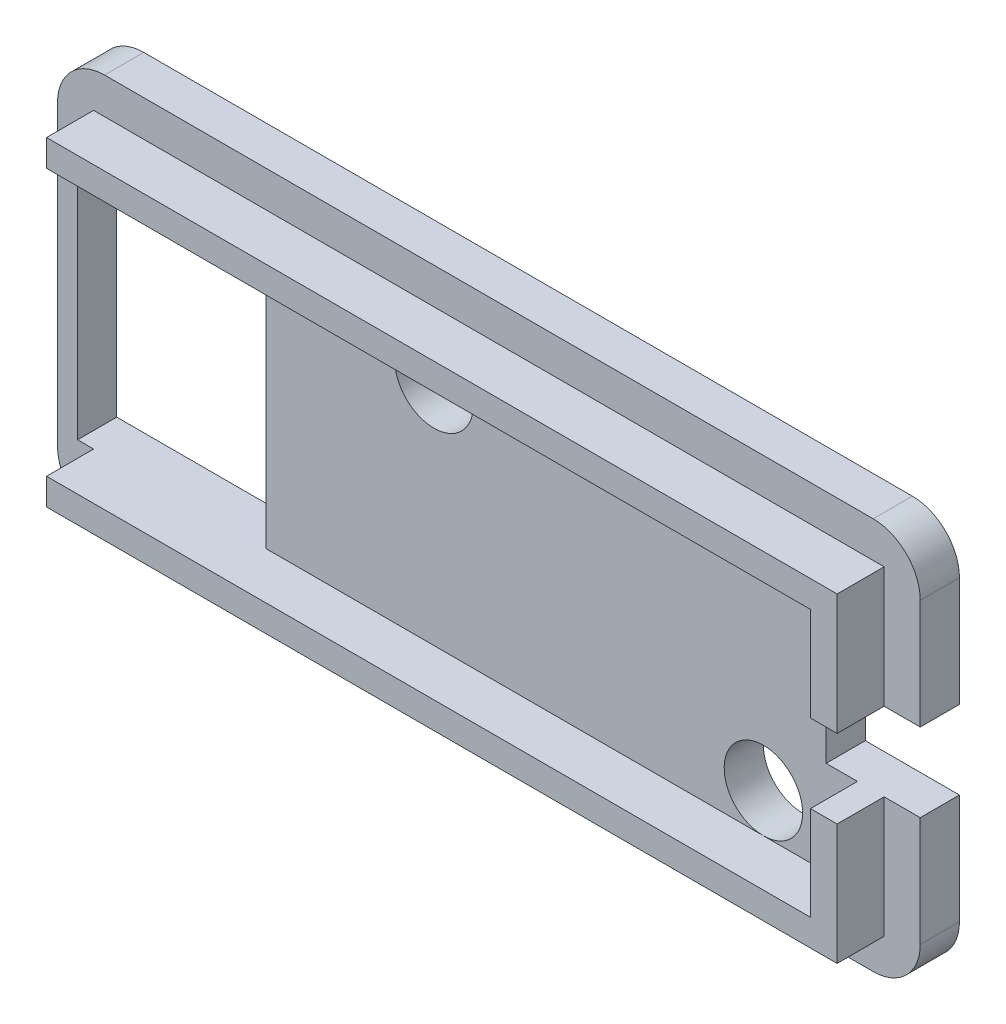
from build123d import *

# Parameters (mm, degrees)
CROQUIS1_W                 = 55
CROQUIS1_H                 = 25
SALIENTE_EXTRUIR1_DEPTH    = 2.5
CROQUIS7_W                 = 51
CROQUIS7_H                 = 21
CROQUIS7_W_2               = 47
CROQUIS7_H_2               = 17
SALIENTE_EXTRUIR4_DEPTH    = 3
REDONDEO2_R                = 3
CROQUIS8_W                 = 12
CROQUIS8_H                 = 17
CORTAR_EXTRUIR5_DEPTH      = 11
CORTAR_EXTRUIR5_DEPTH_BACK = 8
CROQUIS9_W                 = 6
CROQUIS9_H                 = 5
CORTAR_EXTRUIR6_DEPTH      = 8
CROQUIS11_R                = 2.5
CORTAR_EXTRUIR8_DEPTH      = 3.5
CROQUIS12_W                = 51
CROQUIS12_H                = 21
CROQUIS12_W_2              = 50.4
CROQUIS12_H_2              = 20.4
CORTAR_EXTRUIR11_DEPTH     = 3


with BuildPart() as part:
    # Croquis1 → Saliente-Extruir1 (new body)
    with BuildSketch(Plane.XY):
        Rectangle(CROQUIS1_W, CROQUIS1_H)
    extrude(amount=SALIENTE_EXTRUIR1_DEPTH)

    # Croquis7 → Saliente-Extruir4 (add)
    with BuildSketch(Plane.XY.offset(2.5)):
        Rectangle(CROQUIS7_W, CROQUIS7_H)
        Rectangle(CROQUIS7_W_2, CROQUIS7_H_2, mode=Mode.SUBTRACT)
    extrude(amount=SALIENTE_EXTRUIR4_DEPTH)

    # Redondeo2
    redondeo2_edges = [part.edges().sort_by_distance(p)[0] for p in [
        (-27.5, -12.5, 1.25),
        (-27.5, 12.5, 1.25),
        (27.5, 12.5, 1.25),
        (27.5, -12.5, 1.25),
    ]]
    fillet(redondeo2_edges, radius=REDONDEO2_R)

    # Croquis8 → Cortar-Extruir5 (cut, two sides)
    with BuildSketch(Plane.XY.offset(2.5)) as cortar_extruir5_sk:
        with Locations((-20.225004992, 0)):
            Rectangle(CROQUIS8_W, CROQUIS8_H)
    extrude(amount=CORTAR_EXTRUIR5_DEPTH, mode=Mode.SUBTRACT)
    extrude(cortar_extruir5_sk.sketch, amount=-CORTAR_EXTRUIR5_DEPTH_BACK, mode=Mode.SUBTRACT)

    # Croquis9 → Cortar-Extruir6 (cut)
    with BuildSketch(Plane(origin=(0, 0, 0), x_dir=(-1, 0, 0), z_dir=(0, 0, -1))):
        with Locations((-24.5, 0)):
            Rectangle(CROQUIS9_W, CROQUIS9_H)
    extrude(amount=-CORTAR_EXTRUIR6_DEPTH, mode=Mode.SUBTRACT)

    # Croquis11 → Cortar-Extruir8 (cut, through all)
    with BuildSketch(Plane.XY.offset(2.5)):
        with Locations((-3.5, 6)):
            Circle(CROQUIS11_R)
        with Locations((17.5, -6)):
            Circle(CROQUIS11_R)
    extrude(amount=-CORTAR_EXTRUIR8_DEPTH, mode=Mode.SUBTRACT)

    # Croquis12 → Cortar-Extruir11 (cut)
    with BuildSketch(Plane.XY.offset(5.5)):
        Rectangle(CROQUIS12_W, CROQUIS12_H)
        Rectangle(CROQUIS12_W_2, CROQUIS12_H_2, mode=Mode.SUBTRACT)
    extrude(amount=-CORTAR_EXTRUIR11_DEPTH, mode=Mode.SUBTRACT)


solid = part.part
